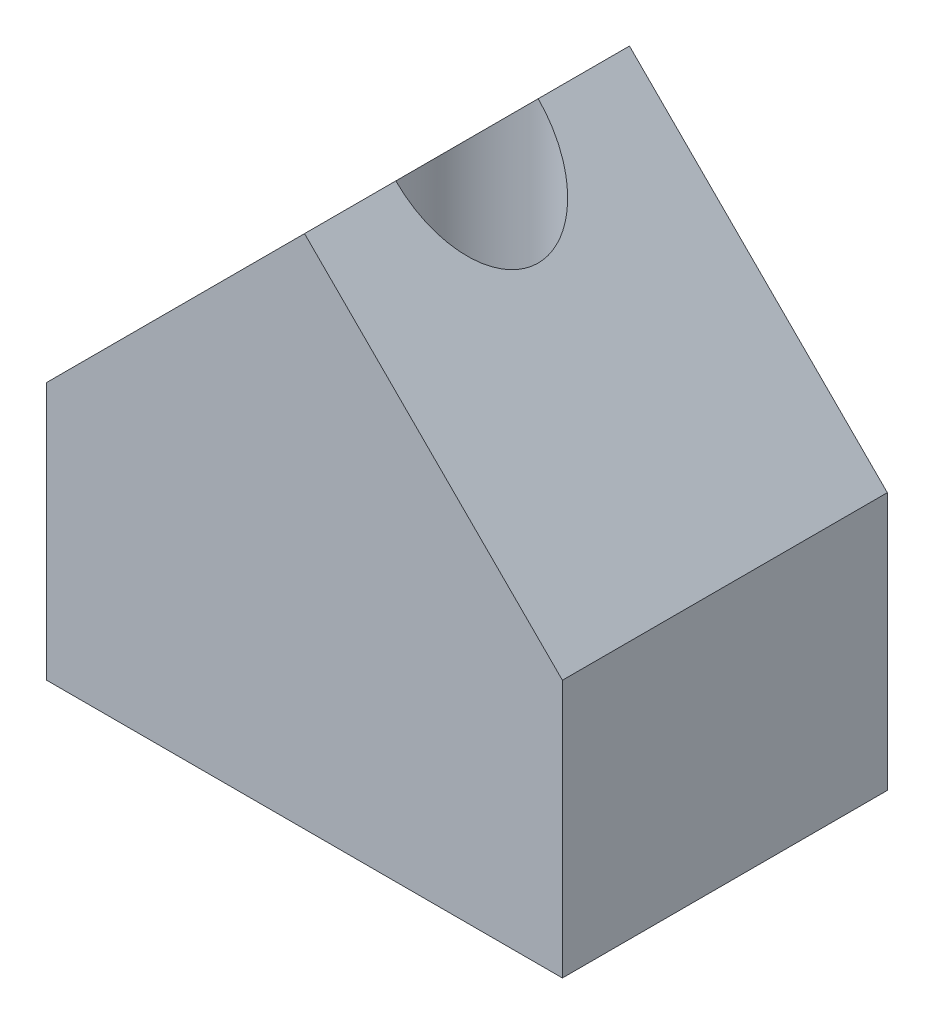
from build123d import *

# Parameters (mm, degrees)
BOSS_EXTRUDE1_DEPTH       = 8.001
SKETCH2_R                 = 1.7526
F_25_20_TAPPED_HOLE_DEPTH = 13.7


with BuildPart() as part:
    # Sketch1 → Boss-Extrude1 (new body)
    with BuildSketch(Plane.XY):
        Polygon((6.35, 0), (0, 6.35), (-6.35, 0), (-6.35, -6.35), (6.35, -6.35), align=None)
    extrude(amount=BOSS_EXTRUDE1_DEPTH)

    # Sketch2 → .25-20 tapped hole (cut, through all)
    with BuildSketch(Plane.XZ.offset(6.35)):
        with Locations((0, 4.0005)):
            Circle(SKETCH2_R)
    extrude(amount=-F_25_20_TAPPED_HOLE_DEPTH, mode=Mode.SUBTRACT)


solid = part.part
